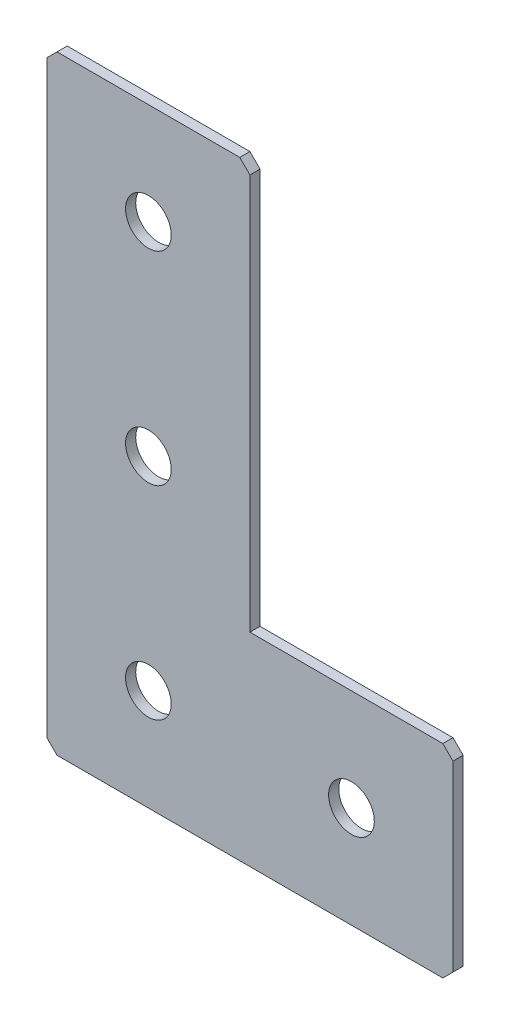
from build123d import *

# Parameters (mm, degrees)
EXTRUDE_1_DEPTH   = 2
HOLE_WIZARD_M81_D = 9
CHAMFER_1_SIZE    = 2


with BuildPart() as part:
    # Эскиз1 → Бобышка-Вытянуть1 (new body)
    with BuildSketch(Plane(origin=(0, 0, 0), x_dir=(1, 0, 0), z_dir=(0, 0, -1))):
        Polygon((0, 0), (0, 120), (80, 120), (80, 80), (40, 80), (40, 0), align=None)
    extrude(amount=EXTRUDE_1_DEPTH)

    # Отверстие с зазором M81 (through all)
    with Locations(Plane(origin=(0, 0, -2), x_dir=(1, 0, 0), z_dir=(0, 0, -1))):
        with Locations((60, 100), (20, 100), (20, 60), (20, 20)):
            Hole(HOLE_WIZARD_M81_D / 2)

    # Фаска1
    chamfer_1_edges = [part.edges().sort_by_distance(p)[0] for p in [
        (0, 0, -1),
        (0, -120, -1),
        (80, -120, -1),
        (80, -80, -1),
        (40, 0, -1),
    ]]
    chamfer(chamfer_1_edges, length=CHAMFER_1_SIZE)


solid = part.part
